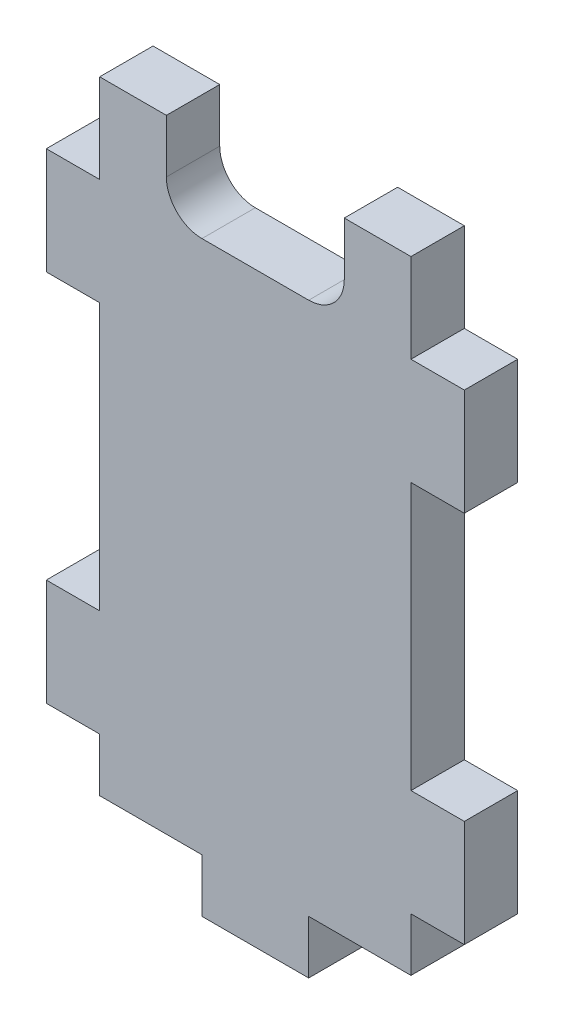
from build123d import *

# Parameters (mm, degrees)
SKETCH1_W           = 6
SKETCH1_H           = 6
BOSS_EXTRUDE1_DEPTH = 6
SKETCH1_3_W         = 6
SKETCH1_3_H         = 12
BOSS_EXTRUDE2_DEPTH = 6
FILLET2_R           = 4


with BuildPart() as part:
    # Sketch1 → Boss-Extrude1 (new body)
    with BuildSketch(Plane.XY):
        Polygon((-17.5, 35), (-17.5, -35), (0, 0), align=None)
        Polygon((-10, 35), (-17.5, 35), (0, 0), (17.5, 35), (10, 35), (10, 25), (-10, 25), align=None)
        Polygon((0, 0), (17.5, -35), (17.5, -29), (17.5, -17), (17.5, 13), (17.5, 25), (17.5, 35), align=None)
        Polygon((-6, -35), (0, -35), (6, -35), (17.5, -35), (0, 0), (-17.5, -35), align=None)
        with Locations((3, -38)):
            Rectangle(SKETCH1_W, SKETCH1_H)
        with Locations((-3, -38)):
            Rectangle(SKETCH1_W, SKETCH1_H)
    extrude(amount=-BOSS_EXTRUDE1_DEPTH)

    # Sketch1_3 → Boss-Extrude2 (add)
    with BuildSketch(Plane.XY):
        with Locations((20.5, 19)):
            Rectangle(SKETCH1_3_W, SKETCH1_3_H)
        with Locations((20.5, -23)):
            Rectangle(SKETCH1_3_W, SKETCH1_3_H)
    boss_extrude2 = extrude(amount=-BOSS_EXTRUDE2_DEPTH)

    # Mirror1: Boss-Extrude2 across plane
    add(boss_extrude2.mirror(Plane(origin=(0, 0, 0), x_dir=(0, 0, 1), z_dir=(1, 0, 0))))

    # Fillet2
    fillet2_edges = [part.edges().sort_by_distance(p)[0] for p in [
        (-10, 25, -3),
        (10, 25, -3),
    ]]
    fillet(fillet2_edges, radius=FILLET2_R)


solid = part.part
